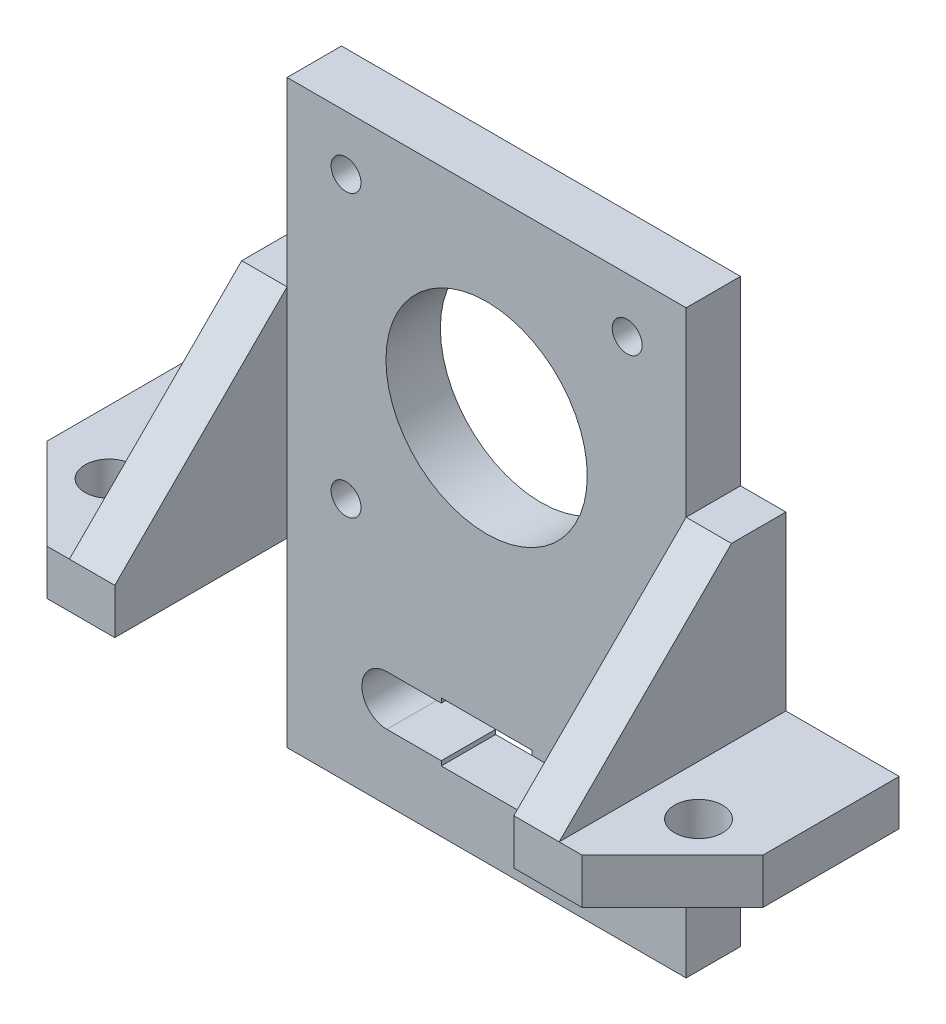
from build123d import *

# Parameters (mm, degrees)
ESBO_O1_R                = 1.65
ESBO_O1_R_2              = 11.1
RESSALTO_EXTRUS_O1_DEPTH = 6
RESSALTO_EXTRUS_O2_DEPTH = 19
CHANFRO1_SIZE            = 10
CHANFRO2_SIZE            = 19
CORTE_EXTRUS_O1_REACH    = 66.197
ESBO_O3_R                = 2.65


with BuildPart() as part:
    # Esboço1 → Ressalto-extrusão1 (new body)
    with BuildSketch(Plane.XY):
        Polygon((39.50000006, -17.500000656), (39.50000006, -22.500000656), (22.00000006, -22.500000656), (22.00000006, -42.500000656), (-21.99999994, -42.500000656), (-21.99999994, -22.500000656), (-39.49999994, -22.500000656), (-39.49999994, -17.500000656), (-26.99999994, -17.500000656), (-26.99999994, 1.499999344), (-21.99999994, 1.499999344), (-21.99999994, 21.499999344), (22.00000006, 21.499999344), (22.00000006, 1.499999344), (27.00000006, 1.499999344), (27.00000006, -17.500000656), align=None)
        with Locations((15.50000006, 15.499999344)):
            Circle(ESBO_O1_R, mode=Mode.SUBTRACT)
        with Locations((15.50000006, -15.500000656)):
            Circle(ESBO_O1_R, mode=Mode.SUBTRACT)
        with Locations((-15.49999994, 15.499999344)):
            Circle(ESBO_O1_R, mode=Mode.SUBTRACT)
        with Locations((-15.49999994, -15.500000656)):
            Circle(ESBO_O1_R, mode=Mode.SUBTRACT)
        Circle(ESBO_O1_R_2, mode=Mode.SUBTRACT)
        with BuildLine():
            Line((-4.99999994, -35.250000656), (-4.99999994, -35.750000656))
            Line((-4.99999994, -35.750000656), (5.00000006, -35.750000656))
            Line((5.00000006, -35.750000656), (5.00000006, -35.250000656))
            Line((5.00000006, -35.250000656), (11.00000006, -35.250000656))
            ThreePointArc((11.00000006, -35.250000656), (13.75000006, -32.500000656), (11.00000006, -29.750000656))
            Line((11.00000006, -29.750000656), (5.00000006, -29.750000656))
            Line((5.00000006, -29.750000656), (5.00000006, -29.250000656))
            Line((5.00000006, -29.250000656), (-4.99999994, -29.250000656))
            Line((-4.99999994, -29.250000656), (-4.99999994, -29.750000656))
            Line((-4.99999994, -29.750000656), (-10.99999994, -29.750000656))
            ThreePointArc((-10.99999994, -29.750000656), (-13.74999994, -32.500000656), (-10.99999994, -35.250000656))
            Line((-10.99999994, -35.250000656), (-4.99999994, -35.250000656))
        make_face(mode=Mode.SUBTRACT)
    extrude(amount=RESSALTO_EXTRUS_O1_DEPTH)

    # Esboço2 → Ressalto-extrusão2 (add)
    with BuildSketch(Plane.XY.offset(6)):
        Polygon((39.50000006, -22.500000656), (39.50000006, -17.500000656), (27.00000006, -17.500000656), (27.00000006, 1.499999344), (22.00000006, 1.499999344), (22.00000006, -22.500000656), align=None)
        Polygon((-39.49999994, -22.500000656), (-21.99999994, -22.500000656), (-21.99999994, 1.499999344), (-26.99999994, 1.499999344), (-26.99999994, -17.500000656), (-39.49999994, -17.500000656), align=None)
    extrude(amount=RESSALTO_EXTRUS_O2_DEPTH)

    # Chanfro1
    chanfro1_edges = [part.edges().sort_by_distance(p)[0] for p in [
        (39.50000006, -20.000000656, 25),
        (-39.49999994, -20.000000656, 25),
    ]]
    chamfer(chanfro1_edges, length=CHANFRO1_SIZE)

    # Chanfro2
    chanfro2_edges = [part.edges().sort_by_distance(p)[0] for p in [
        (-24.49999994, 1.499999344, 25),
        (24.50000006, 1.499999344, 25),
    ]]
    chamfer(chanfro2_edges, length=CHANFRO2_SIZE)

    # Esboço3 → Corte-extrusão1 (cut, up to next)
    with BuildSketch(Plane.XZ.offset(22.500000656), mode=Mode.PRIVATE) as corte_extrus_o1_sk1:
        with Locations((32.50000006, 15.13)):
            Circle(ESBO_O3_R)
    corte_extrus_o1_tool1 = extrude(corte_extrus_o1_sk1.sketch, amount=-CORTE_EXTRUS_O1_REACH, mode=Mode.PRIVATE) & part.part
    # Esboço3 → Corte-extrusão1 (cut, up to next)
    with BuildSketch(Plane.XZ.offset(22.500000656), mode=Mode.PRIVATE) as corte_extrus_o1_sk2:
        with Locations((-32.49999994, 15.13)):
            Circle(ESBO_O3_R)
    corte_extrus_o1_tool2 = extrude(corte_extrus_o1_sk2.sketch, amount=-CORTE_EXTRUS_O1_REACH, mode=Mode.PRIVATE) & part.part
    add(corte_extrus_o1_tool1.solids().sort_by_distance((32.5, -22.500001, 15.13))[0], mode=Mode.SUBTRACT)
    add(corte_extrus_o1_tool2.solids().sort_by_distance((-32.5, -22.500001, 15.13))[0], mode=Mode.SUBTRACT)


solid = part.part
